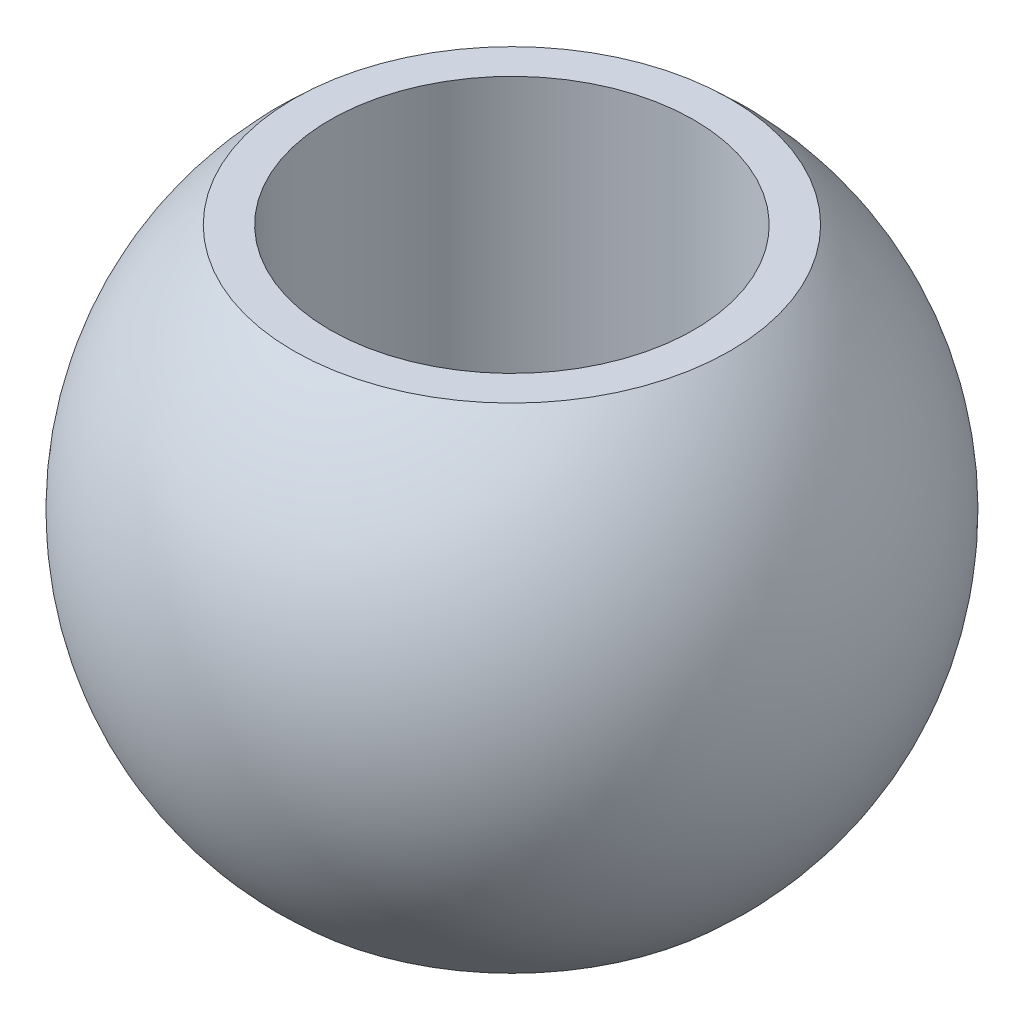
from build123d import *


with BuildPart() as part:
    # Szkic1 → Obrót1 (revolve)
    with BuildSketch(Plane.XY):
        with BuildLine():
            Line((7, -9.5), (7, 9.5))
            Line((7, 9.5), (8.398356982, 9.5))
            ThreePointArc((8.398356982, 9.5), (12.68, 0), (8.398356982, -9.5))
            Line((8.398356982, -9.5), (7, -9.5))
        make_face()
    revolve(axis=Axis((0, -11.1, 0), (0, 1, 0)))


solid = part.part
